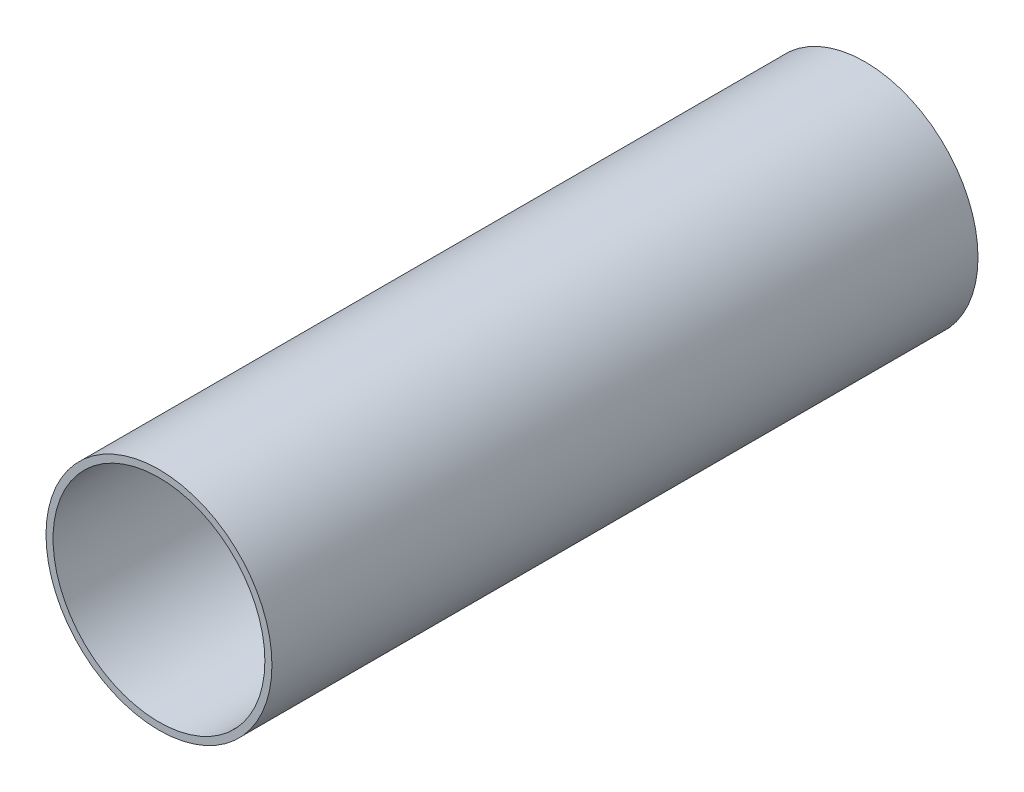
from build123d import *

# Parameters (mm, degrees)
SKETCH1_R           = 32
SKETCH1_R_2         = 30
BOSS_EXTRUDE1_DEPTH = 200


with BuildPart() as part:
    # Sketch1 → Boss-Extrude1 (new body)
    with BuildSketch(Plane.XY):
        Circle(SKETCH1_R)
        Circle(SKETCH1_R_2, mode=Mode.SUBTRACT)
    extrude(amount=BOSS_EXTRUDE1_DEPTH)


solid = part.part
